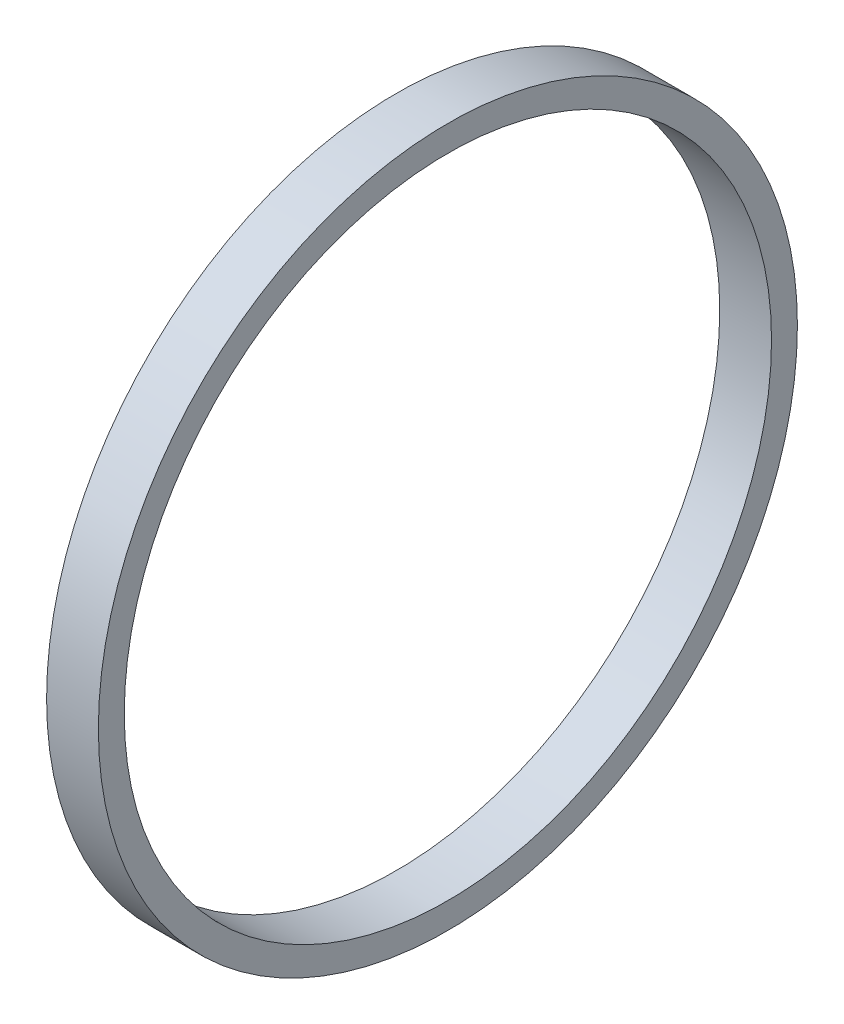
from build123d import *

# Parameters (mm, degrees)
SKETCH1_R           = 13.5
SKETCH1_R_2         = 12.5
BOSS_EXTRUDE1_DEPTH = 2


with BuildPart() as part:
    # Sketch1 → Boss-Extrude1 (new body)
    with BuildSketch(Plane(origin=(0, 0, 0), x_dir=(0, 0, -1), z_dir=(1, 0, 0))):
        Circle(SKETCH1_R)
        Circle(SKETCH1_R_2, mode=Mode.SUBTRACT)
    extrude(amount=BOSS_EXTRUDE1_DEPTH)


solid = part.part
